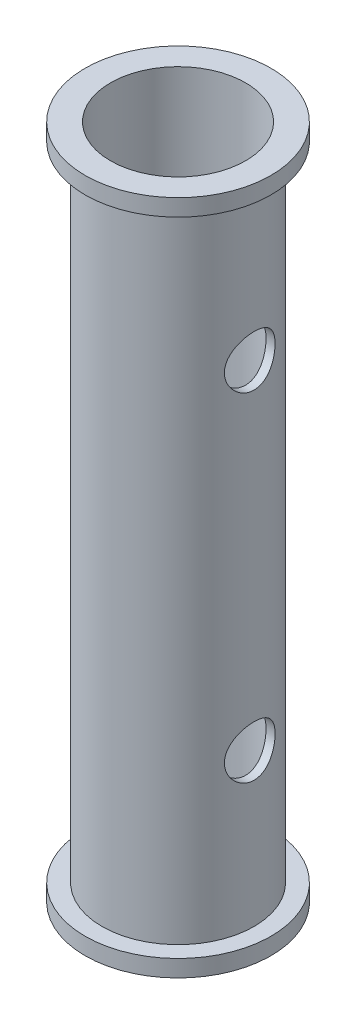
from build123d import *

# Parameters (mm, degrees)
SKETCH1_R           = 5.5
SKETCH1_R_2         = 4
BOSS_EXTRUDE1_DEPTH = 1
SKETCH1_3_R         = 4.5
SKETCH1_3_R_2       = 4
BOSS_EXTRUDE2_DEPTH = 40
BOSS_EXTRUDE3_START = 39
SKETCH1_4_R         = 5.5
SKETCH1_4_R_2       = 4.5
BOSS_EXTRUDE3_DEPTH = 1
SKETCH2_R           = 1.5
CUT_EXTRUDE1_DEPTH  = 32


with BuildPart() as part:
    # Sketch1 → Boss-Extrude1 (new body)
    with BuildSketch(Plane(origin=(0, 0, 0), x_dir=(1, 0, 0), z_dir=(0, 1, 0))):
        Circle(SKETCH1_R)
        Circle(SKETCH1_R_2, mode=Mode.SUBTRACT)
    extrude(amount=BOSS_EXTRUDE1_DEPTH)

    # Sketch1_3 → Boss-Extrude2 (add)
    with BuildSketch(Plane(origin=(0, 0, 0), x_dir=(1, 0, 0), z_dir=(0, 1, 0))):
        Circle(SKETCH1_3_R)
        Circle(SKETCH1_3_R_2, mode=Mode.SUBTRACT)
    extrude(amount=BOSS_EXTRUDE2_DEPTH)

    # Sketch1_4 → Boss-Extrude3 (add)
    with BuildSketch(Plane(origin=(0, 0, 0), x_dir=(1, 0, 0), z_dir=(0, 1, 0)).offset(BOSS_EXTRUDE3_START)):
        Circle(SKETCH1_4_R)
        Circle(SKETCH1_4_R_2, mode=Mode.SUBTRACT)
    extrude(amount=BOSS_EXTRUDE3_DEPTH)

    # Sketch2 → Cut-Extrude1 (cut)
    with BuildSketch(Plane(origin=(4.5, 0, 0), x_dir=(0, 0, -1), z_dir=(1, 0, 0))):
        with Locations((0, 10)):
            Circle(SKETCH2_R)
        with Locations((0, 30)):
            Circle(SKETCH2_R)
    extrude(amount=-CUT_EXTRUDE1_DEPTH, mode=Mode.SUBTRACT)


solid = part.part
